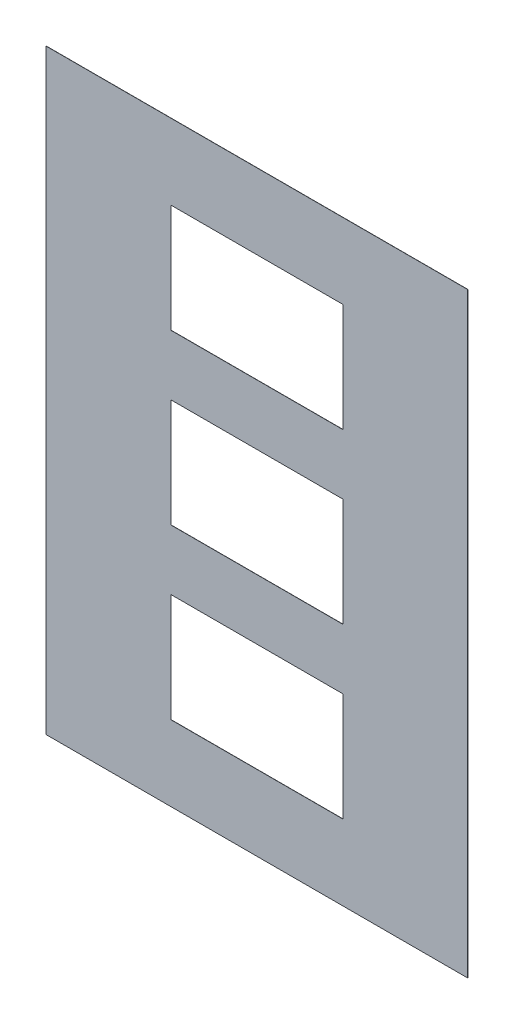
from build123d import *

# Parameters (mm, degrees)
SKETCH_1_W             = 210
SKETCH_1_H             = 297
EXTRUDE_1_DEPTH        = 0.1
SKETCH_2_W             = 85.6
SKETCH_2_H             = 54
CUT_EXTRUDE_1_DEPTH    = 8
PATTERN_LINEAR_1_COUNT = 3
PATTERN_LINEAR_1_PITCH = 84


with BuildPart() as part:
    # 草图1 → 凸台-拉伸1 (new body)
    with BuildSketch(Plane.XY):
        with Locations((105, 148.5)):
            Rectangle(SKETCH_1_W, SKETCH_1_H)
    extrude(amount=EXTRUDE_1_DEPTH)

    # 草图2 → 切除-拉伸1 (cut)
    with BuildSketch(Plane.XY.offset(0.1)):
        with Locations((105, 64.5)):
            Rectangle(SKETCH_2_W, SKETCH_2_H)
    cut_extrude_1 = extrude(amount=-CUT_EXTRUDE_1_DEPTH, mode=Mode.SUBTRACT)

    # 阵列(线性)1: 切除-拉伸1 ×3
    with Locations(*[(0, i * PATTERN_LINEAR_1_PITCH, 0) for i in range(1, PATTERN_LINEAR_1_COUNT)]):
        add(cut_extrude_1, mode=Mode.SUBTRACT)


solid = part.part
